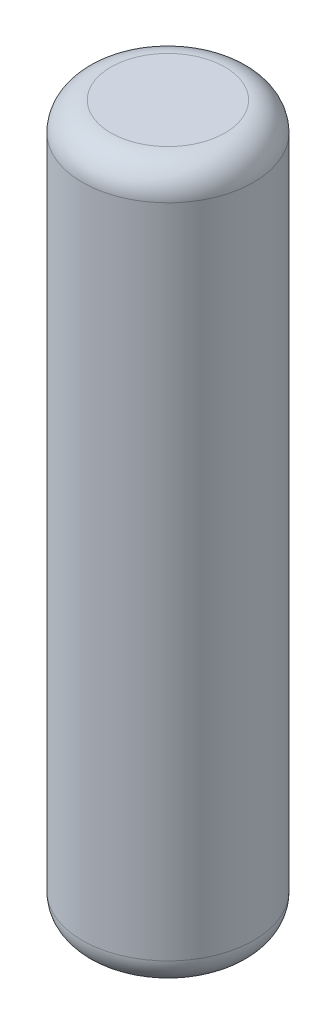
from build123d import *

# Parameters (mm, degrees)
SKETCH1_R           = 30
BOSS_EXTRUDE1_DEPTH = 250
FILLET1_R           = 10


with BuildPart() as part:
    # Sketch1 → Boss-Extrude1 (new body)
    with BuildSketch(Plane(origin=(0, 0, 0), x_dir=(1, 0, 0), z_dir=(0, 1, 0))):
        Circle(SKETCH1_R)
    extrude(amount=BOSS_EXTRUDE1_DEPTH)

    # Fillet1
    fillet1_edges = [part.edges().sort_by_distance(p)[0] for p in [
        (-30, 0, 0),
        (-30, 250, 0),
    ]]
    fillet(fillet1_edges, radius=FILLET1_R)


solid = part.part
